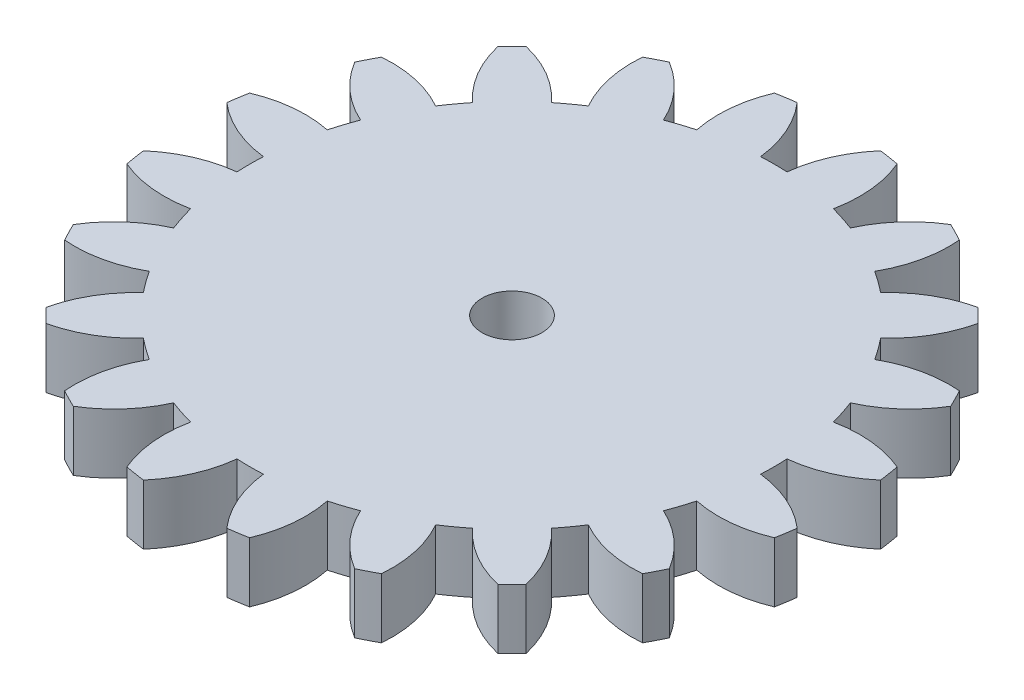
from build123d import *

# Parameters (mm, degrees)
SKETCH1_R           = 16.5
BOSS_EXTRUDE1_DEPTH = 3
CUT_EXTRUDE1_DEPTH  = 4
CIRPATTERN1_COUNT   = 20
SKETCH4_R           = 1.5
CUT_EXTRUDE3_DEPTH  = 10


with BuildPart() as part:
    # Sketch1 → Boss-Extrude1 (new body)
    with BuildSketch(Plane(origin=(0, 0, 0), x_dir=(1, 0, 0), z_dir=(0, 1, 0))):
        Circle(SKETCH1_R)
    extrude(amount=BOSS_EXTRUDE1_DEPTH)

    # Sketch2 → Cut-Extrude1 (cut, through all)
    with BuildSketch(Plane(origin=(0, 3, 0), x_dir=(1, 0, 0), z_dir=(0, 1, 0))):
        with BuildLine():
            ThreePointArc((-0.661599664, 13.108314571), (0, 13.125), (0.661599664, 13.108314571))
            ThreePointArc((0.661599664, 13.108314571), (1.127215597, 14.845961564), (2.087005275, 16.367480227))
            ThreePointArc((2.087005275, 16.367480227), (0, 16.5), (-2.087005275, 16.367480227))
            ThreePointArc((-2.087005275, 16.367480227), (-1.127215597, 14.845961564), (-0.661599664, 13.108314571))
        make_face()
    cut_extrude1 = extrude(amount=-CUT_EXTRUDE1_DEPTH, mode=Mode.SUBTRACT)

    # CirPattern1: Cut-Extrude1 ×20 about axis
    cirpattern1_axis = Axis((0, 0, 0), (0, 1, 0))
    for i in range(1, CIRPATTERN1_COUNT):
        add(cut_extrude1.rotate(cirpattern1_axis, i * 360 / CIRPATTERN1_COUNT), mode=Mode.SUBTRACT)

    # Sketch4 → Cut-Extrude3 (cut)
    with BuildSketch(Plane.XZ):
        Circle(SKETCH4_R)
    extrude(amount=-CUT_EXTRUDE3_DEPTH, mode=Mode.SUBTRACT)


solid = part.part
